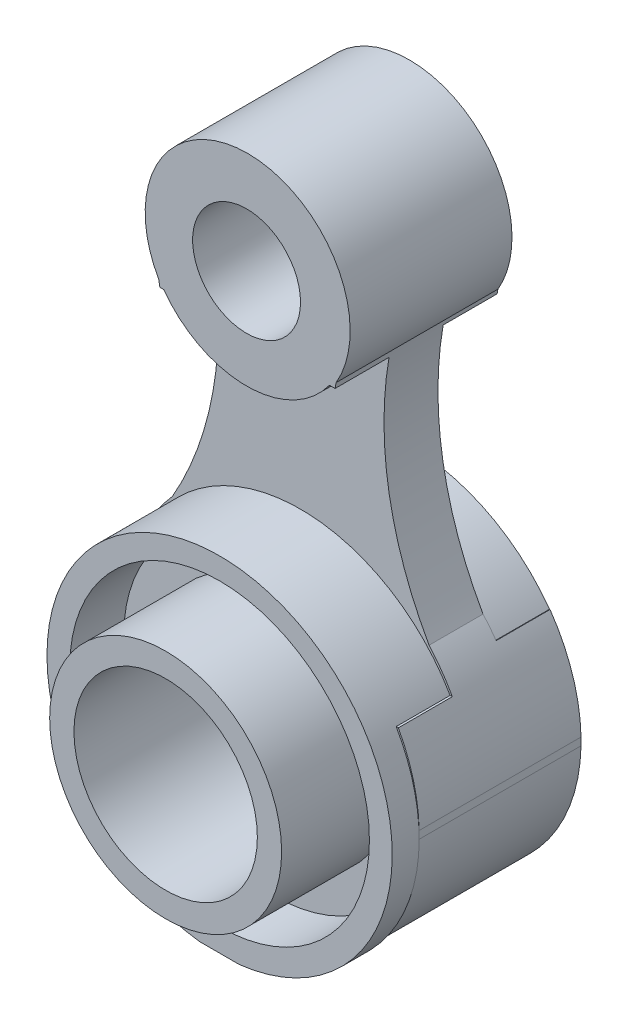
from build123d import *

# Parameters (mm, degrees)
ESQUISSE1_W              = 64
ESQUISSE1_H              = 126
BOSS_EXTRU_1_DEPTH       = 45
ESQUISSE2_W              = 74.759642061
ESQUISSE2_H              = 139.382383503
ESQUISSE2_R              = 32
ENL_V_MAT_EXTRU_2_DEPTH  = 15
ESQUISSE3_R              = 27.5
ENL_V_MAT_EXTRU_5_DEPTH  = 10
ESQUISSE5_R              = 27.775
ESQUISSE5_R_2            = 21.5
ENL_V_MAT_EXTRU_7_DEPTH  = 20
ESQUISSE6_R              = 17
ENL_V_MAT_EXTRU_8_DEPTH  = 84.773504165
ESQUISSE7_R              = 10
ENL_V_MAT_EXTRU_9_DEPTH  = 77.765877836
ESQUISSE8_W              = 86.397385067
ESQUISSE8_H              = 136.429769075
ENL_V_MAT_EXTRU_11_DEPTH = 77.765877836
ENL_V_MAT_EXTRU_12_DEPTH = 10
ENL_V_MAT_EXTRU_13_DEPTH = 10


with BuildPart() as part:
    # Esquisse1 → Boss.-Extru.1 (new body)
    with BuildSketch(Plane.XY):
        Rectangle(ESQUISSE1_W, ESQUISSE1_H)
    extrude(amount=BOSS_EXTRU_1_DEPTH)

    # Esquisse2 → Enlèv. mat.-Extru.2 (cut)
    with BuildSketch(Plane.XY.offset(45)):
        with Locations((-0.51685586, -5.363099381)):
            Rectangle(ESQUISSE2_W, ESQUISSE2_H)
        with Locations((0, -31.212195959)):
            Circle(ESQUISSE2_R, mode=Mode.SUBTRACT)
    extrude(amount=-ENL_V_MAT_EXTRU_2_DEPTH, mode=Mode.SUBTRACT)

    # Esquisse3 → Enlèv. mat.-Extru.5 (cut)
    with BuildSketch(Plane.XY.offset(45)):
        with BuildLine():
            Line((-3.679064313, -63), (3.679064313, -63))
            ThreePointArc((3.679064313, -63), (0, 0.787804041), (-3.679064313, -63))
        make_face()
        with Locations((0, -31.212195959)):
            Circle(ESQUISSE3_R, mode=Mode.SUBTRACT)
    extrude(amount=-ENL_V_MAT_EXTRU_5_DEPTH, mode=Mode.SUBTRACT)

    # Esquisse5 → Enlèv. mat.-Extru.7 (cut)
    with BuildSketch(Plane.XY.offset(45)):
        with Locations((0, -31)):
            Circle(ESQUISSE5_R)
        with Locations((0, -31)):
            Circle(ESQUISSE5_R_2, mode=Mode.SUBTRACT)
    extrude(amount=-ENL_V_MAT_EXTRU_7_DEPTH, mode=Mode.SUBTRACT)

    # Esquisse6 → Enlèv. mat.-Extru.8 (cut, through all)
    with BuildSketch(Plane.XY.offset(45)):
        with Locations((0, -30.914318574)):
            Circle(ESQUISSE6_R)
    extrude(amount=-ENL_V_MAT_EXTRU_8_DEPTH, mode=Mode.SUBTRACT)

    # Esquisse7 → Enlèv. mat.-Extru.9 (cut, through all)
    with BuildSketch(Plane.XY.offset(30)):
        with Locations((0, 44)):
            Circle(ESQUISSE7_R)
    extrude(amount=-ENL_V_MAT_EXTRU_9_DEPTH, mode=Mode.SUBTRACT)

    # Esquisse8 → Enlèv. mat.-Extru.11 (cut, through all)
    with BuildSketch(Plane.XY.offset(30)):
        with Locations((-1.464362458, -2.806694712)):
            Rectangle(ESQUISSE8_W, ESQUISSE8_H)
        with BuildLine():
            Line((-32, 63), (0.202169279, 63))
            Line((0.202169279, 63), (32, 63))
            Line((32, 63), (32, -29.80290649))
            ThreePointArc((32, -29.80290649), (32.005817879, -30.155207508), (32.00775725, -30.507551224))
            ThreePointArc((32.00775725, -30.507551224), (32.005817879, -30.85989494), (32, -31.212195959))
            ThreePointArc((32, -31.212195959), (0, -62.515308475), (-32, -31.212195959))
            ThreePointArc((-32, -31.212195959), (-32.00775725, -30.507551224), (-32, -29.80290649))
            Line((-32, -29.80290649), (-32, 63))
        make_face(mode=Mode.SUBTRACT)
        with BuildLine():
            ThreePointArc((0.202169279, 63), (13.63719816, 57.435028864), (19.202169338, 44))
            ThreePointArc((19.202169338, 44), (18.538621544, 39.022599022), (16.594325075, 34.392855247))
            ThreePointArc((16.594325075, 34.392855247), (16.343681733, 11.978736432), (23.83747578, -9.147043911))
            ThreePointArc((23.83747578, -9.147043911), (29.76780291, -18.744284921), (32, -29.80290649))
            Line((32, -29.80290649), (32, 63))
            Line((32, 63), (0.202169279, 63))
        make_face()
        with BuildLine():
            ThreePointArc((-18.797830662, 44), (-13.232859525, 57.435028822), (0.202169279, 63))
            Line((0.202169279, 63), (-32, 63))
            Line((-32, 63), (-32, -29.80290649))
            ThreePointArc((-32, -29.80290649), (-29.74748685, -18.693002977), (-23.763712379, -9.065011772))
            ThreePointArc((-23.763712379, -9.065011772), (-16.134588528, 12.08350842), (-16.289948146, 34.565485657))
            ThreePointArc((-16.289948146, 34.565485657), (-18.160159384, 39.118925948), (-18.797830662, 44))
        make_face()
    extrude(amount=-ENL_V_MAT_EXTRU_11_DEPTH, mode=Mode.SUBTRACT)

    # Esquisse10 → Enlèv. mat.-Extru.12 (cut)
    with BuildSketch(Plane.XY.offset(30)):
        with BuildLine():
            Line((-15.358096219, 33.354922672), (-16.07732259, 33.354922672))
            ThreePointArc((-16.07732259, 33.354922672), (-16.24125544, 11.478282043), (-23.763712379, -9.065011772))
            ThreePointArc((-23.763712379, -9.065011772), (-26.135325713, -12.029421609), (-28.139276, -15.253775612))
            Line((-28.139276, -15.253775612), (-27.736777391, -15.253775612))
            ThreePointArc((-27.736777391, -15.253775612), (0, 0.787804041), (27.736777391, -15.253775612))
            Line((27.736777391, -15.253775612), (28.139276, -15.253775612))
            ThreePointArc((28.139276, -15.253775612), (26.167130611, -12.074488543), (23.83747578, -9.147043911))
            ThreePointArc((23.83747578, -9.147043911), (16.432370726, 11.458852589), (16.406556938, 33.354922672))
            Line((16.406556938, 33.354922672), (15.358096219, 33.354922672))
            ThreePointArc((15.358096219, 33.354922672), (0, 25.541024787), (-15.358096219, 33.354922672))
        make_face()
    extrude(amount=-ENL_V_MAT_EXTRU_12_DEPTH, mode=Mode.SUBTRACT)

    # Esquisse11 → Enlèv. mat.-Extru.13 (cut)
    with BuildSketch(Plane(origin=(0, 0, 0), x_dir=(-1, 0, 0), z_dir=(0, 0, -1))):
        with BuildLine():
            Line((-15.504189616, 33.558306347), (-16.441959806, 33.558306347))
            ThreePointArc((-16.441959806, 33.558306347), (-16.41467553, 11.560545546), (-23.83747578, -9.147043911))
            ThreePointArc((-23.83747578, -9.147043911), (-25.093902529, -10.63816321), (-26.257202417, -12.20302049))
            Line((-26.257202417, -12.20302049), (-26.162723497, -12.20302049))
            ThreePointArc((-26.162723497, -12.20302049), (-0.203383675, 1.085681426), (25.755956147, -12.20302049))
            Line((25.755956147, -12.20302049), (26.257202417, -12.20302049))
            ThreePointArc((26.257202417, -12.20302049), (25.059623979, -10.594947923), (23.763712379, -9.065011772))
            ThreePointArc((23.763712379, -9.065011772), (16.222953758, 11.579751881), (16.111372133, 33.558306347))
            Line((16.111372133, 33.558306347), (15.504189616, 33.558306347))
            ThreePointArc((15.504189616, 33.558306347), (0, 25.541024787), (-15.504189616, 33.558306347))
        make_face()
    extrude(amount=-ENL_V_MAT_EXTRU_13_DEPTH, mode=Mode.SUBTRACT)


solid = part.part
